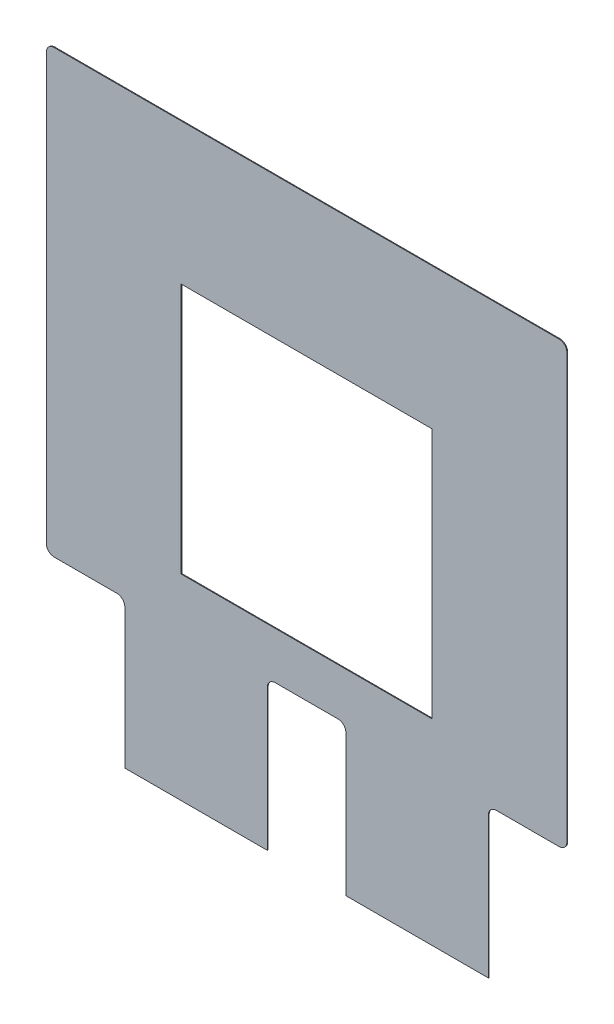
from build123d import *

# Parameters (mm, degrees)
SALIENTE_EXTRUIR1_DEPTH = 0.1


with BuildPart() as part:
    # Model → Saliente-Extruir1 (new body)
    with BuildSketch(Plane.XY):
        with BuildLine():
            Line((34.712434383, 29.082277171), (47.712434383, 29.082277171))
            ThreePointArc((47.712434383, 29.082277171), (48.419541165, 28.789383952), (48.712434383, 28.082277171))
            Line((48.712434383, 28.082277171), (48.712434383, -25.917722829))
            ThreePointArc((48.712434383, -25.917722829), (48.419541165, -26.62482961), (47.712434383, -26.917722829))
            Line((47.712434383, -26.917722829), (39.712434383, -26.917722829))
            ThreePointArc((39.712434383, -26.917722829), (39.005327602, -27.210616048), (38.712434383, -27.917722829))
            Line((38.712434383, -27.917722829), (38.712434383, -45.917722829))
            Line((38.712434383, -45.917722829), (20.548823016, -45.917722829))
            Line((20.548823016, -45.917722829), (20.548823016, -27.917722829))
            ThreePointArc((20.548823016, -27.917722829), (20.255929797, -27.210616048), (19.548823016, -26.917722829))
            Line((19.548823016, -26.917722829), (11.548823016, -26.917722829))
            ThreePointArc((11.548823016, -26.917722829), (10.841716234, -27.210616048), (10.548823016, -27.917722829))
            Line((10.548823016, -27.917722829), (10.548823016, -45.917722829))
            Line((10.548823016, -45.917722829), (-7.614788352, -45.917722829))
            Line((-7.614788352, -45.917722829), (-7.614788352, -28.139448744))
            ThreePointArc((-7.614788352, -28.139448744), (-7.907681571, -27.432341963), (-8.614788352, -27.139448744))
            Line((-8.614788352, -27.139448744), (-16.614788352, -27.139448744))
            ThreePointArc((-16.614788352, -27.139448744), (-17.321895133, -26.846555525), (-17.614788352, -26.139448744))
            Line((-17.614788352, -26.139448744), (-17.614788352, 28.082277171))
            ThreePointArc((-17.614788352, 28.082277171), (-17.321895133, 28.789383952), (-16.614788352, 29.082277171))
            Line((-16.614788352, 29.082277171), (-3.614788352, 29.082277171))
            Line((-3.614788352, 29.082277171), (34.712434383, 29.082277171))
        make_face()
        Polygon((31.548823016, 11.082277171), (31.548823016, -20.917722829), (-0.451176984, -20.917722829), (-0.451176984, 11.082277171), (16.048823016, 11.082277171), align=None, mode=Mode.SUBTRACT)
    extrude(amount=SALIENTE_EXTRUIR1_DEPTH)


solid = part.part
